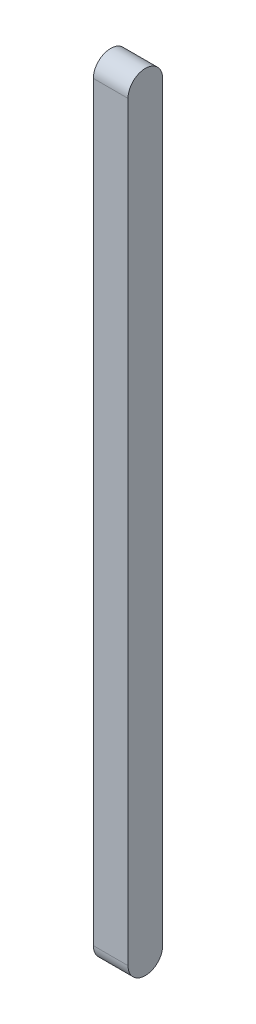
from build123d import *

# Parameters (mm, degrees)
SKETCH1_W           = 30
SKETCH1_H           = 30
BOSS_EXTRUDE1_DEPTH = 650
SKETCH2_R           = 15
BOSS_EXTRUDE2_DEPTH = 30


with BuildPart() as part:
    # Sketch1 → Boss-Extrude1 (new body)
    with BuildSketch(Plane(origin=(0, 0, 0), x_dir=(1, 0, 0), z_dir=(0, 1, 0))):
        Rectangle(SKETCH1_W, SKETCH1_H)
    extrude(amount=BOSS_EXTRUDE1_DEPTH)

    # Sketch2 → Boss-Extrude2 (add)
    with BuildSketch(Plane.ZY.offset(15)):
        Circle(SKETCH2_R)
        with Locations((0, 650)):
            Circle(SKETCH2_R)
    extrude(amount=-BOSS_EXTRUDE2_DEPTH)


solid = part.part
